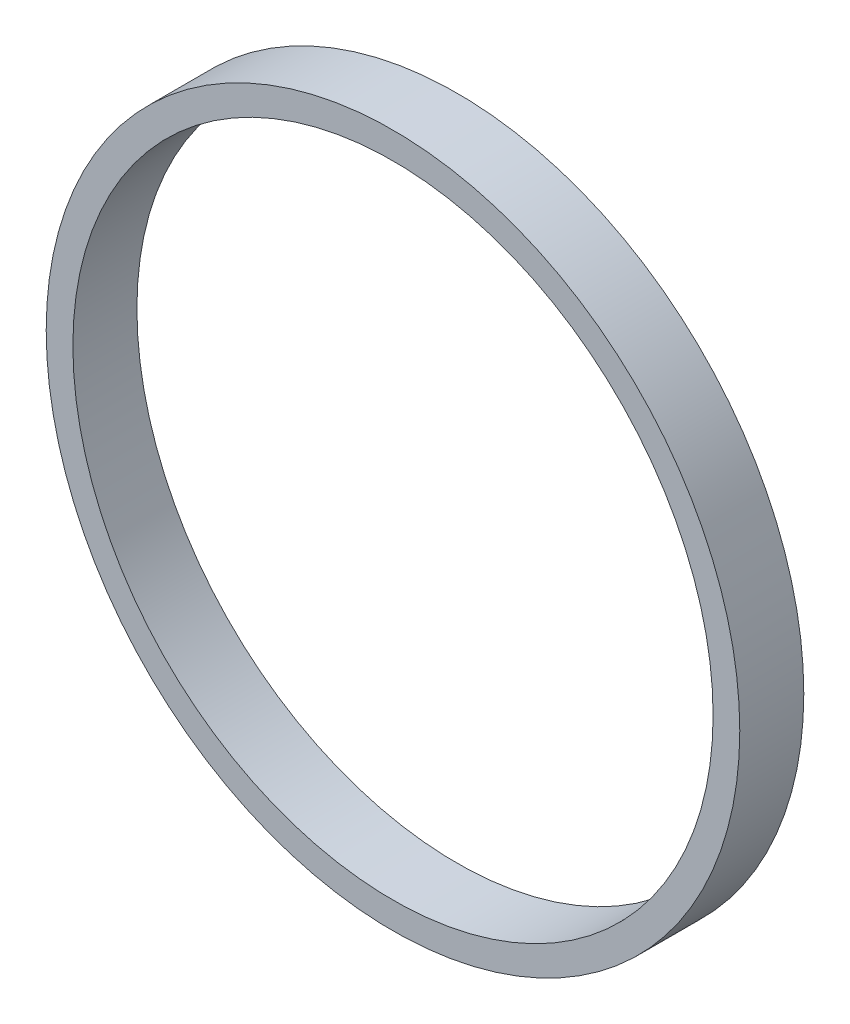
from build123d import *

# Parameters (mm, degrees)
SKETCH1_R           = 32.5
SKETCH1_R_2         = 30
BOSS_EXTRUDE1_DEPTH = 6


with BuildPart() as part:
    # Sketch1 → Boss-Extrude1 (new body)
    with BuildSketch(Plane.XY):
        Circle(SKETCH1_R)
        Circle(SKETCH1_R_2, mode=Mode.SUBTRACT)
    extrude(amount=BOSS_EXTRUDE1_DEPTH)


solid = part.part
